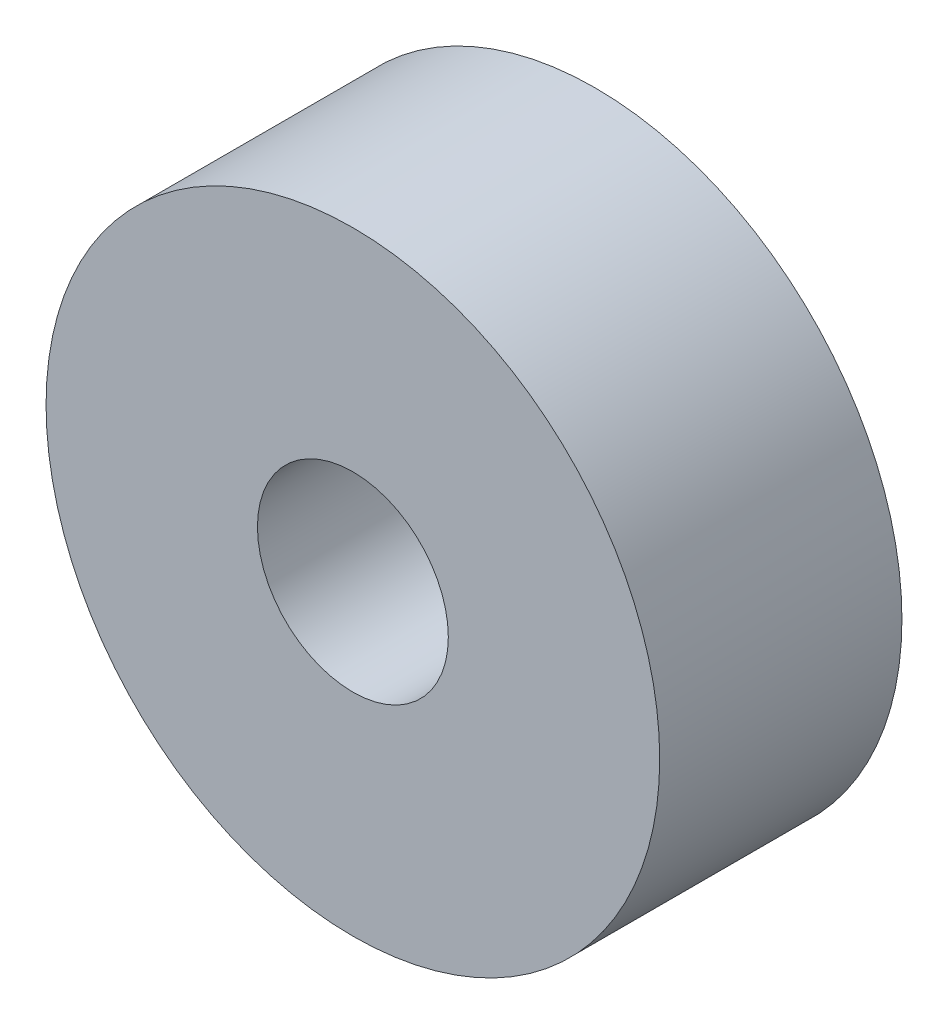
from build123d import *

# Parameters (mm, degrees)
SKETCH1_R          = 9.5
MAIN_EXTRUDE_DEPTH = 7.5
SKETCH2_R          = 2.955
CUT_EXTRUDE1_DEPTH = 10


with BuildPart() as part:
    # Sketch1 → Main Extrude (new body)
    with BuildSketch(Plane.XY):
        Circle(SKETCH1_R)
    extrude(amount=MAIN_EXTRUDE_DEPTH)

    # Sketch2 → Cut-Extrude1 (cut)
    with BuildSketch(Plane.XY.offset(7.5)):
        Circle(SKETCH2_R)
    extrude(amount=-CUT_EXTRUDE1_DEPTH, mode=Mode.SUBTRACT)


solid = part.part
